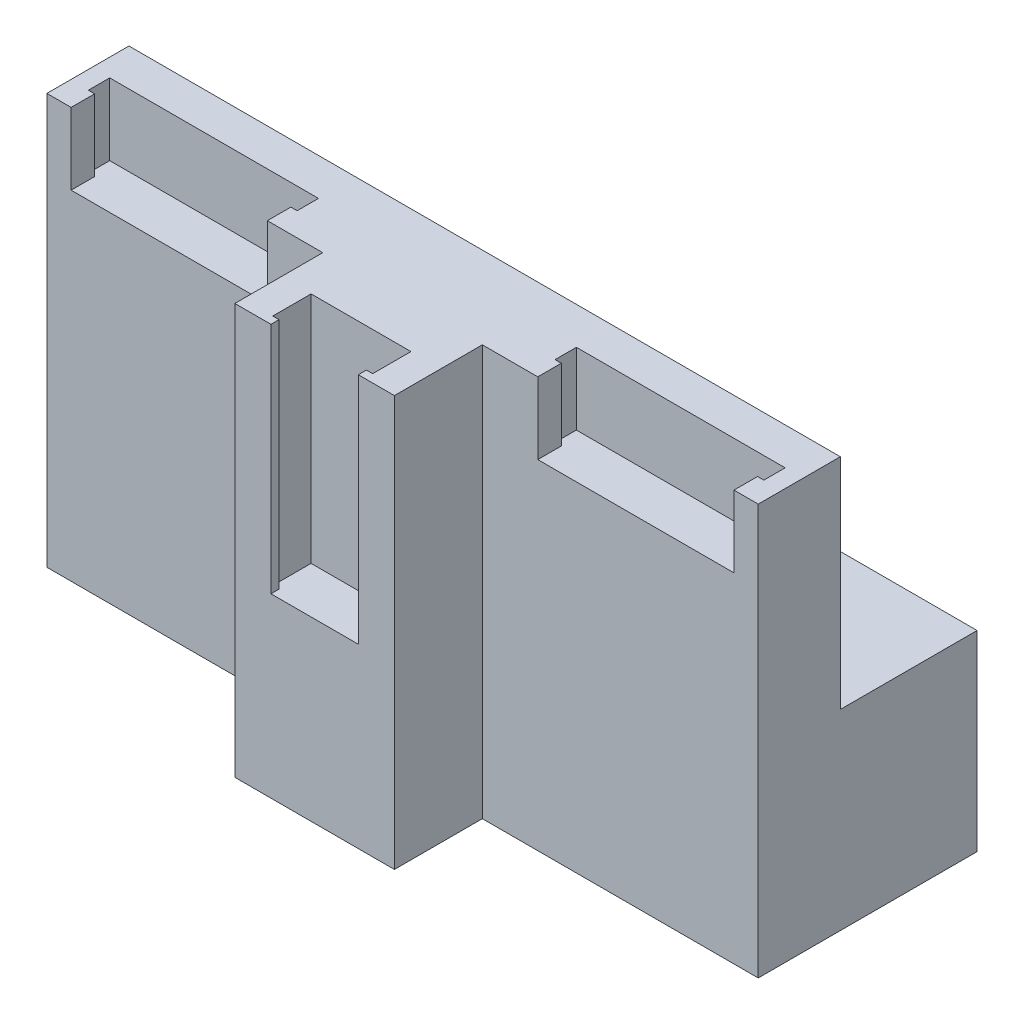
from build123d import *

# Parameters (mm, degrees)
SKETCH2_W           = 130
SKETCH2_H           = 40
BOSS_EXTRUDE1_DEPTH = 75
SKETCH6_W           = 29.16
SKETCH6_H           = 49.32
BOSS_EXTRUDE2_DEPTH = 16.07
SKETCH7_W           = 15.96
SKETCH7_H           = 42.65
CUT_EXTRUDE1_DEPTH  = 8.48
SKETCH8_W           = 7
SKETCH8_H           = 42.65
CUT_EXTRUDE2_DEPTH  = 1.145
SKETCH9_W           = 7
SKETCH9_H           = 42.65
CUT_EXTRUDE3_DEPTH  = 1.145
SKETCH11_W          = 35.86
SKETCH11_H          = 21.1
CUT_EXTRUDE4_DEPTH  = 8.2
SKETCH13_W          = 3.9
SKETCH13_H          = 21.1
CUT_EXTRUDE5_DEPTH  = 1.145
SKETCH14_W          = 3.9
SKETCH14_H          = 21.1
CUT_EXTRUDE6_DEPTH  = 1.145
SKETCH15_W          = 35.86
SKETCH15_H          = 21.1
CUT_EXTRUDE7_DEPTH  = 8.2
SKETCH16_W          = 3.9
SKETCH16_H          = 21.1
CUT_EXTRUDE8_DEPTH  = 1.145
SKETCH17_W          = 3.9
SKETCH17_H          = 21.1
CUT_EXTRUDE9_DEPTH  = 1.145
SKETCH20_W          = 29.16
SKETCH20_H          = 16.07
BOSS_EXTRUDE3_DEPTH = 25.68
SKETCH21_W          = 40
SKETCH21_H          = 25
CUT_EXTRUDE10_DEPTH = 40
SKETCH22_W          = 50
SKETCH22_H          = 25
CUT_EXTRUDE11_DEPTH = 40
BOSS_EXTRUDE4_DEPTH = 8
BOSS_EXTRUDE5_DEPTH = 8


with BuildPart() as part:
    # Sketch2 → Boss-Extrude1 (new body)
    with BuildSketch(Plane(origin=(0, 0, 0), x_dir=(1, 0, 0), z_dir=(0, 1, 0))):
        Rectangle(SKETCH2_W, SKETCH2_H)
    extrude(amount=BOSS_EXTRUDE1_DEPTH)

    # Sketch6 → Boss-Extrude2 (add)
    with BuildSketch(Plane.XY.offset(20)):
        with Locations((0, 50.34)):
            Rectangle(SKETCH6_W, SKETCH6_H)
    extrude(amount=BOSS_EXTRUDE2_DEPTH)

    # Sketch7 → Cut-Extrude1 (cut)
    with BuildSketch(Plane.XY.offset(36.07)):
        with Locations((0, 53.675)):
            Rectangle(SKETCH7_W, SKETCH7_H)
    extrude(amount=-CUT_EXTRUDE1_DEPTH, mode=Mode.SUBTRACT)

    # Sketch8 → Cut-Extrude2 (cut)
    with BuildSketch(Plane(origin=(-7.98, 0, 0), x_dir=(0, 0, -1), z_dir=(1, 0, 0))):
        with Locations((-31.09, 53.675)):
            Rectangle(SKETCH8_W, SKETCH8_H)
    extrude(amount=-CUT_EXTRUDE2_DEPTH, mode=Mode.SUBTRACT)

    # Sketch9 → Cut-Extrude3 (cut)
    with BuildSketch(Plane.ZY.offset(-7.98)):
        with Locations((31.09, 53.675)):
            Rectangle(SKETCH9_W, SKETCH9_H)
    extrude(amount=-CUT_EXTRUDE3_DEPTH, mode=Mode.SUBTRACT)

    # Sketch11 → Cut-Extrude4 (cut)
    with BuildSketch(Plane.XY.offset(20)):
        with Locations((42.64, 64.45)):
            Rectangle(SKETCH11_W, SKETCH11_H)
    extrude(amount=-CUT_EXTRUDE4_DEPTH, mode=Mode.SUBTRACT)

    # Sketch13 → Cut-Extrude5 (cut)
    with BuildSketch(Plane(origin=(24.71, 0, 0), x_dir=(0, 0, -1), z_dir=(1, 0, 0))):
        with Locations((-13.75, 64.45)):
            Rectangle(SKETCH13_W, SKETCH13_H)
    extrude(amount=-CUT_EXTRUDE5_DEPTH, mode=Mode.SUBTRACT)

    # Sketch14 → Cut-Extrude6 (cut)
    with BuildSketch(Plane.ZY.offset(-60.57)):
        with Locations((13.75, 64.45)):
            Rectangle(SKETCH14_W, SKETCH14_H)
    extrude(amount=-CUT_EXTRUDE6_DEPTH, mode=Mode.SUBTRACT)

    # Sketch15 → Cut-Extrude7 (cut)
    with BuildSketch(Plane.XY.offset(20)):
        with Locations((-42.64, 64.45)):
            Rectangle(SKETCH15_W, SKETCH15_H)
    extrude(amount=-CUT_EXTRUDE7_DEPTH, mode=Mode.SUBTRACT)

    # Sketch16 → Cut-Extrude8 (cut)
    with BuildSketch(Plane(origin=(-60.57, 0, 0), x_dir=(0, 0, -1), z_dir=(1, 0, 0))):
        with Locations((-13.75, 64.45)):
            Rectangle(SKETCH16_W, SKETCH16_H)
    extrude(amount=-CUT_EXTRUDE8_DEPTH, mode=Mode.SUBTRACT)

    # Sketch17 → Cut-Extrude9 (cut)
    with BuildSketch(Plane.ZY.offset(24.71)):
        with Locations((13.75, 64.45)):
            Rectangle(SKETCH17_W, SKETCH17_H)
    extrude(amount=-CUT_EXTRUDE9_DEPTH, mode=Mode.SUBTRACT)

    # Sketch20 → Boss-Extrude3 (add)
    with BuildSketch(Plane(origin=(0, 25.68, 0), x_dir=(-1, 0, 0), z_dir=(0, -1, 0))):
        with Locations((0, -28.035)):
            Rectangle(SKETCH20_W, SKETCH20_H)
    extrude(amount=BOSS_EXTRUDE3_DEPTH)

    # Sketch21 → Cut-Extrude10 (cut)
    with BuildSketch(Plane(origin=(0, 75, 0), x_dir=(1, 0, 0), z_dir=(0, 1, 0))):
        with Locations((45, 7.5)):
            Rectangle(SKETCH21_W, SKETCH21_H)
        with Locations((-45, 7.5)):
            Rectangle(SKETCH21_W, SKETCH21_H)
    extrude(amount=-CUT_EXTRUDE10_DEPTH, mode=Mode.SUBTRACT)

    # Sketch22 → Cut-Extrude11 (cut)
    with BuildSketch(Plane(origin=(0, 75, 0), x_dir=(1, 0, 0), z_dir=(0, 1, 0))):
        with Locations((0, 7.5)):
            Rectangle(SKETCH22_W, SKETCH22_H)
    extrude(amount=-CUT_EXTRUDE11_DEPTH, mode=Mode.SUBTRACT)

    # Sketch23 → Boss-Extrude4 (add)
    with BuildSketch(Plane(origin=(0, 53.9, 0), x_dir=(1, 0, 0), z_dir=(0, 1, 0))):
        Polygon((-60.57, -20), (-60.57, -15.7), (-61.715, -15.7), (-61.715, -11.8), (-23.565, -11.8), (-23.565, -15.7), (-24.71, -15.7), (-24.71, -20), align=None)
    extrude(amount=BOSS_EXTRUDE4_DEPTH)

    # Sketch24 → Boss-Extrude5 (add)
    with BuildSketch(Plane(origin=(0, 53.9, 0), x_dir=(1, 0, 0), z_dir=(0, 1, 0))):
        Polygon((24.71, -20), (24.71, -15.7), (23.565, -15.7), (23.565, -11.8), (61.715, -11.8), (61.715, -15.7), (60.57, -15.7), (60.57, -20), align=None)
    extrude(amount=BOSS_EXTRUDE5_DEPTH)


solid = part.part
